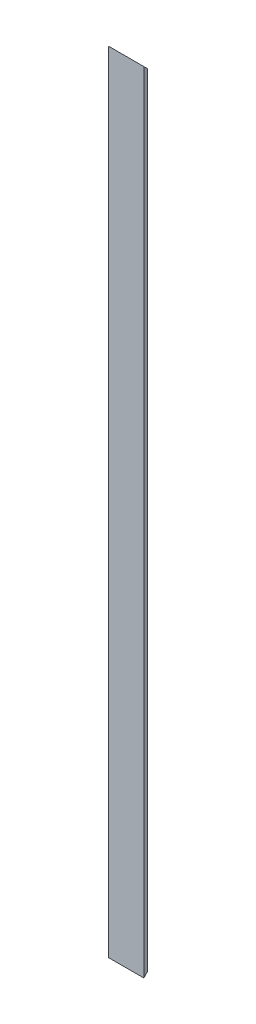
from build123d import *

# Parameters (mm, degrees)
EXTRUDE_1_DEPTH     = 1000
CUT_EXTRUDE_1_DEPTH = 46


with BuildPart() as part:
    # Эскиз1 → Вытянуть-Тонкостенный1 (new body)
    with BuildSketch(Plane(origin=(0, 0, 0), x_dir=(1, 0, 0), z_dir=(0, 1, 0))):
        Polygon((0, 45), (0, 0), (45, 0), (45, 5), (5, 5), (5, 45), align=None)
    extrude(amount=EXTRUDE_1_DEPTH)

    # Эскиз2 → Вырез-Вытянуть1 (cut, through all)
    with BuildSketch(Plane.ZY):
        Polygon((0, 0), (-45, 45), (-45, 0), align=None)
        Polygon((-45, 1000), (0, 1000), (-45, 955), align=None)
    extrude(amount=-CUT_EXTRUDE_1_DEPTH, mode=Mode.SUBTRACT)


solid = part.part
